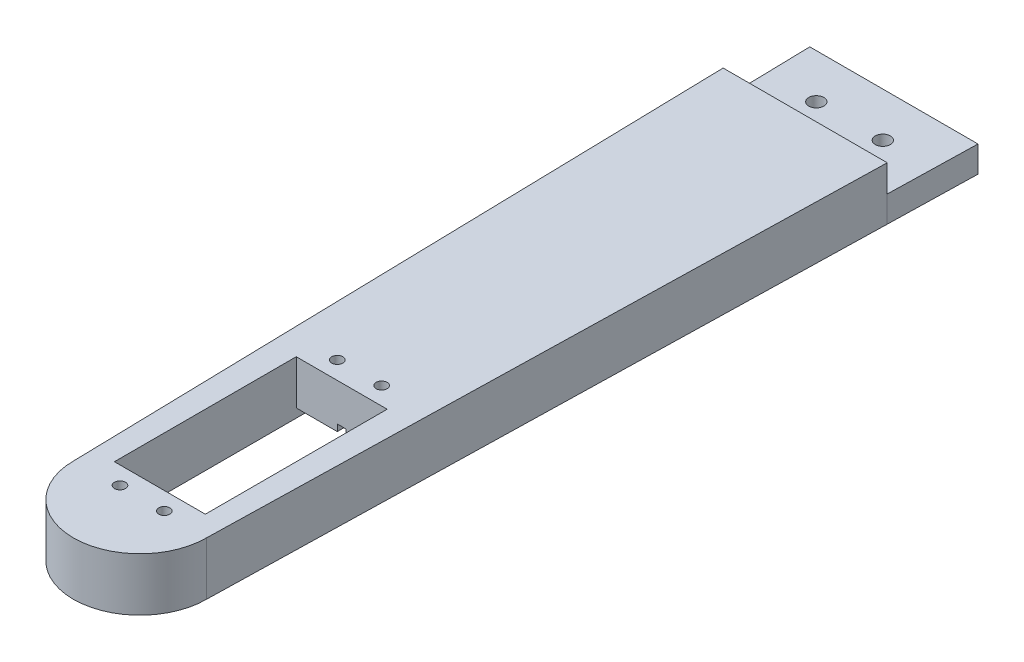
from build123d import *

# Parameters (mm, degrees)
BOSS_EXTRUDE1_DEPTH = 12
BOSS_EXTRUDE2_DEPTH = 5.9
SKETCH3_R           = 1.7
CUT_EXTRUDE1_DEPTH  = 5.9
CUT_EXTRUDE2_DEPTH  = 3
SKETCH5_W           = 20.5
SKETCH5_H           = 41
CUT_EXTRUDE3_DEPTH  = 12
SKETCH6_W           = 20.5
SKETCH6_H           = 55
CUT_EXTRUDE4_DEPTH  = 2
SKETCH7_W           = 2
SKETCH7_H           = 7
CUT_EXTRUDE5_DEPTH  = 1.5
SKETCH8_R           = 1.25
CUT_EXTRUDE6_DEPTH  = 12


with BuildPart() as part:
    # Sketch1 → Boss-Extrude1 (new body)
    with BuildSketch(Plane(origin=(0, 0, 0), x_dir=(1, 0, 0), z_dir=(0, 1, 0))):
        with BuildLine():
            Line((18.5, 75), (-18.5, 75))
            Line((-18.5, 75), (-15, -75))
            ThreePointArc((-15, -75), (0, -90), (15, -75))
            Line((15, -75), (18.5, 75))
        make_face()
    extrude(amount=BOSS_EXTRUDE1_DEPTH)

    # Sketch2 → Boss-Extrude2 (add)
    with BuildSketch(Plane.XZ):
        Polygon((-18.965, -95), (18.965, -95), (18.5, -75), (-18.5, -75), align=None)
        with BuildLine():
            Line((-18.5, -75), (18.5, -75))
            Line((18.5, -75), (15, 75))
            ThreePointArc((15, 75), (0, 90), (-15, 75))
            Line((-15, 75), (-18.5, -75))
        make_face()
    extrude(amount=-BOSS_EXTRUDE2_DEPTH)

    # Sketch3 → Cut-Extrude1 (cut)
    with BuildSketch(Plane.XZ):
        with Locations((-7.5, -85)):
            Circle(SKETCH3_R)
        with Locations((7.5, -85)):
            Circle(SKETCH3_R)
    extrude(amount=-CUT_EXTRUDE1_DEPTH, mode=Mode.SUBTRACT)

    # Sketch4 → Cut-Extrude2 (cut)
    with BuildSketch(Plane.XZ):
        Polygon((-7.5, -81.766838493), (-10.3, -83.383419246), (-10.3, -86.616580754), (-7.5, -88.233161507), (-4.7, -86.616580754), (-4.7, -83.383419246), align=None)
        Polygon((7.5, -81.766838493), (4.7, -83.383419246), (4.7, -86.616580754), (7.5, -88.233161507), (10.3, -86.616580754), (10.3, -83.383419246), align=None)
    extrude(amount=-CUT_EXTRUDE2_DEPTH, mode=Mode.SUBTRACT)

    # Sketch5 → Cut-Extrude3 (cut)
    with BuildSketch(Plane.XZ):
        with Locations((0, 50)):
            Rectangle(SKETCH5_W, SKETCH5_H)
    extrude(amount=-CUT_EXTRUDE3_DEPTH, mode=Mode.SUBTRACT)

    # Sketch6 → Cut-Extrude4 (cut)
    with BuildSketch(Plane.XZ):
        with Locations((0, 50)):
            Rectangle(SKETCH6_W, SKETCH6_H)
    extrude(amount=-CUT_EXTRUDE4_DEPTH, mode=Mode.SUBTRACT)

    # Sketch7 → Cut-Extrude5 (cut)
    with BuildSketch(Plane.XZ.offset(-2)):
        with Locations((0, 74)):
            Rectangle(SKETCH7_W, SKETCH7_H)
        with Locations((0, 26)):
            Rectangle(SKETCH7_W, SKETCH7_H)
    extrude(amount=-CUT_EXTRUDE5_DEPTH, mode=Mode.SUBTRACT)

    # Sketch8 → Cut-Extrude6 (cut)
    with BuildSketch(Plane.XZ.offset(-2)):
        with Locations((-5, 74.5)):
            Circle(SKETCH8_R)
        with Locations((5, 74.5)):
            Circle(SKETCH8_R)
        with Locations((5, 25.5)):
            Circle(SKETCH8_R)
        with Locations((-5, 25.5)):
            Circle(SKETCH8_R)
    extrude(amount=-CUT_EXTRUDE6_DEPTH, mode=Mode.SUBTRACT)


solid = part.part
